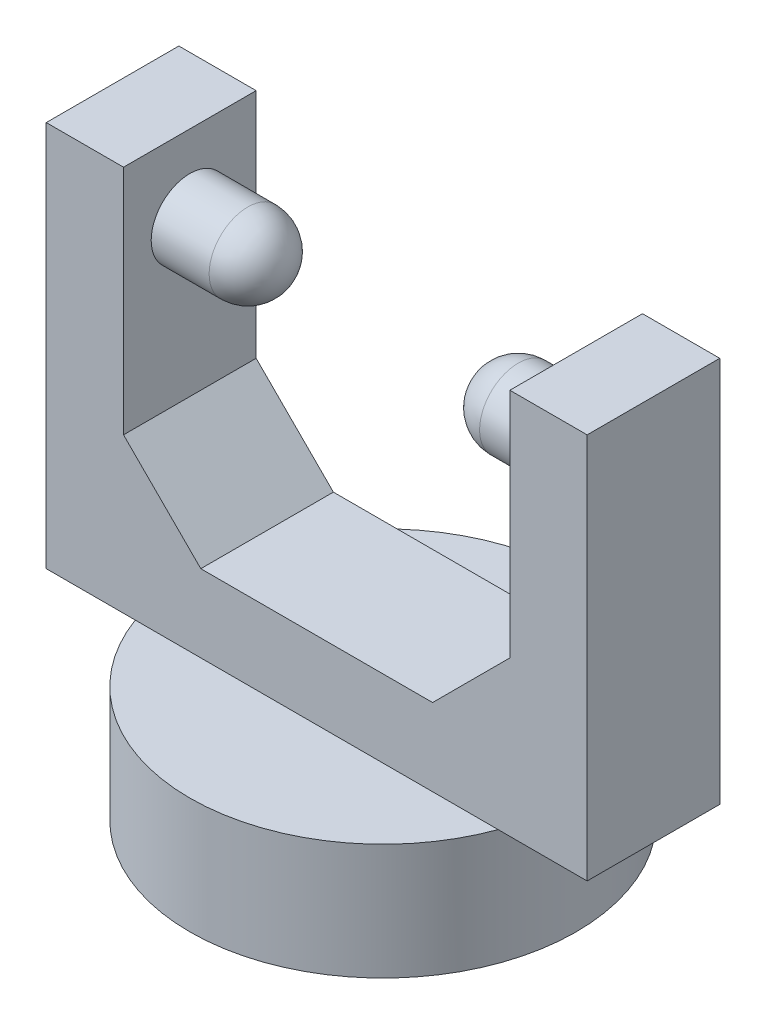
from build123d import *

# Parameters (mm, degrees)
SKETCH1_R           = 12.5
BOSS_EXTRUDE1_DEPTH = 7.5
SKETCH2_W           = 35
SKETCH2_H           = 8.580767914
BOSS_EXTRUDE2_DEPTH = 25
SKETCH3_W           = 25
SKETCH3_H           = 8.580767914
CUT_EXTRUDE1_DEPTH  = 20
SKETCH4_R           = 2.5
BOSS_EXTRUDE3_DEPTH = 6.25
SKETCH5_R           = 2.5
BOSS_EXTRUDE4_DEPTH = 6.25
CHAMFER1_SIZE       = 5
CHAMFER2_SIZE       = 5
FILLET1_R           = 2.5
FILLET2_R           = 2.5


with BuildPart() as part:
    # Sketch1 → Boss-Extrude1 (new body)
    with BuildSketch(Plane(origin=(0, 0, 0), x_dir=(1, 0, 0), z_dir=(0, 1, 0))):
        Circle(SKETCH1_R)
    extrude(amount=BOSS_EXTRUDE1_DEPTH)

    # Sketch2 → Boss-Extrude2 (add)
    with BuildSketch(Plane(origin=(0, 7.5, 0), x_dir=(1, 0, 0), z_dir=(0, 1, 0))):
        Rectangle(SKETCH2_W, SKETCH2_H)
    extrude(amount=BOSS_EXTRUDE2_DEPTH)

    # Sketch3 → Cut-Extrude1 (cut)
    with BuildSketch(Plane(origin=(0, 32.5, 0), x_dir=(1, 0, 0), z_dir=(0, 1, 0))):
        Rectangle(SKETCH3_W, SKETCH3_H)
    extrude(amount=-CUT_EXTRUDE1_DEPTH, mode=Mode.SUBTRACT)

    # Sketch4 → Boss-Extrude3 (add)
    with BuildSketch(Plane(origin=(-12.5, 0, 0), x_dir=(0, 0, -1), z_dir=(1, 0, 0))):
        with Locations((0, 27.5)):
            Circle(SKETCH4_R)
    extrude(amount=BOSS_EXTRUDE3_DEPTH)

    # Sketch5 → Boss-Extrude4 (add)
    with BuildSketch(Plane.ZY.offset(-12.5)):
        with Locations((0, 27.5)):
            Circle(SKETCH5_R)
    extrude(amount=BOSS_EXTRUDE4_DEPTH)

    # Chamfer1
    chamfer1_edges = [part.edges().sort_by_distance(p)[0] for p in [
        (-12.5, 12.5, 0),
    ]]
    chamfer(chamfer1_edges, length=CHAMFER1_SIZE)

    # Chamfer2
    chamfer2_edges = [part.edges().sort_by_distance(p)[0] for p in [
        (12.5, 12.5, 0),
    ]]
    chamfer(chamfer2_edges, length=CHAMFER2_SIZE)

    # Fillet1
    fillet1_edges = [part.edges().sort_by_distance(p)[0] for p in [
        (-6.25, 27.5, 2.5),
    ]]
    fillet(fillet1_edges, radius=FILLET1_R)

    # Fillet2
    fillet2_edges = [part.edges().sort_by_distance(p)[0] for p in [
        (6.25, 27.5, -2.5),
    ]]
    fillet(fillet2_edges, radius=FILLET2_R)


solid = part.part
